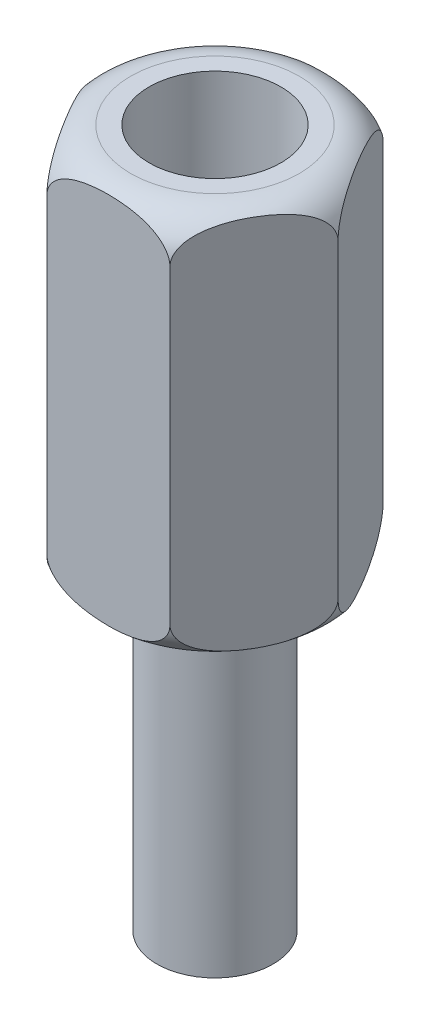
from build123d import *

# Parameters (mm, degrees)
BOSS_EXTRUDE1_DEPTH      = 10
M3_CLEARANCE_HOLE1_D     = 3.4
M3_CLEARANCE_HOLE1_DEPTH = 12
M3_CLEARANCE_HOLE1_TIP   = 1.021463052
SKETCH5_R                = 1.5
BOSS_EXTRUDE2_DEPTH      = 8


with BuildPart() as part:
    # Sketch1 → Boss-Extrude1 (new body)
    with BuildSketch(Plane(origin=(0, 0, 0), x_dir=(1, 0, 0), z_dir=(0, 1, 0))):
        Polygon((3.175426481, 0), (1.58771324, 2.75), (-1.58771324, 2.75), (-3.175426481, 0), (-1.58771324, -2.75), (1.58771324, -2.75), align=None)
    extrude(amount=BOSS_EXTRUDE1_DEPTH)

    # M3 Clearance Hole1
    with Locations(Plane(origin=(0, 10, 0), x_dir=(-1, 0, 0), z_dir=(0, 1, 0))):
        with Locations((0, 0)):
            Hole(M3_CLEARANCE_HOLE1_D / 2, depth=M3_CLEARANCE_HOLE1_DEPTH)
            with Locations((0, 0, -(M3_CLEARANCE_HOLE1_DEPTH + M3_CLEARANCE_HOLE1_TIP / 2))):  # 118° drill point
                Cone(0, M3_CLEARANCE_HOLE1_D / 2, M3_CLEARANCE_HOLE1_TIP, mode=Mode.SUBTRACT)

    # Sketch4 → Cut-Revolve1 (revolve, cut)
    with BuildSketch(Plane.XY):
        with BuildLine():
            Line((-2.175426481, 10), (-3.175426481, 10))
            Line((-3.175426481, 10), (-3.175426481, 9))
            ThreePointArc((-3.175426481, 9), (-2.882533262, 9.707106781), (-2.175426481, 10))
        make_face()
        with BuildLine():
            Line((-3.175426481, 1), (-3.175426481, 0))
            Line((-3.175426481, 0), (-2.175426481, 0))
            ThreePointArc((-2.175426481, 0), (-2.882533262, 0.292893219), (-3.175426481, 1))
        make_face()
    revolve(axis=Axis((0, 10, 0), (0, -1, 0)), mode=Mode.SUBTRACT)


with BuildPart() as body_2:
    # Sketch5 → Boss-Extrude2 (new body)
    with BuildSketch(Plane.XZ):
        Circle(SKETCH5_R)
    extrude(amount=BOSS_EXTRUDE2_DEPTH)


solid = Compound([part.part, body_2.part])
